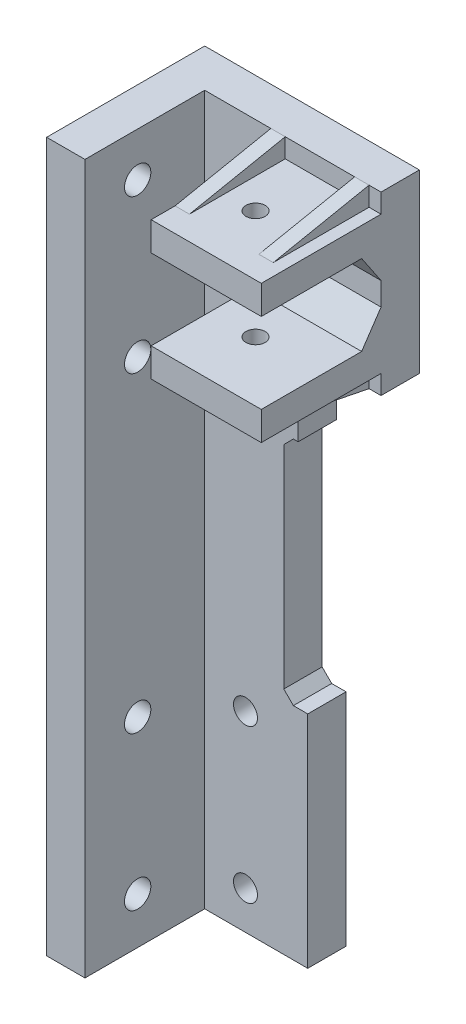
from build123d import *

# Parameters (mm, degrees)
SKETCH1_W               = 24.51
SKETCH1_H               = 148
BOSS_EXTRUDE1_DEPTH     = 8
SKETCH2_W               = 8
SKETCH2_H               = 148
BOSS_EXTRUDE2_DEPTH     = 25
SKETCH4_W               = 20.3
SKETCH4_H               = 36.8
BOSS_EXTRUDE3_DEPTH     = 8
SKETCH5_W               = 23
SKETCH5_H               = 6
BOSS_EXTRUDE4_DEPTH     = 25
CUT_EXTRUDE2_REACH      = 151.752
SKETCH6_R               = 2
RIB1_REACH              = 159.03
SKETCH8_WALL_W          = 336.456302216
SKETCH8_WALL_H          = 3
MIRROR2_COPY_1_REACH    = 159.03
MIRROR2_COPY_1_SKETCH_W = 336.456302216
MIRROR2_COPY_1_SKETCH_H = 3
SKETCH3_R               = 2.5
CUT_EXTRUDE1_DEPTH      = 10
SKETCH12_R              = 2.75
CUT_EXTRUDE3_DEPTH      = 8
SKETCH13_W              = 5
SKETCH13_H              = 46
BOSS_EXTRUDE5_DEPTH     = 8
SKETCH14_W              = 3
SKETCH14_H              = 17
BOSS_EXTRUDE6_DEPTH     = 8
CHAMFER1_SIZE           = 2
CHAMFER2_SIZE           = 6
CHAMFER2_SIZE2          = 4.047051101


with BuildPart() as part:
    # Sketch1 → Boss-Extrude1 (new body)
    with BuildSketch(Plane.XY):
        with Locations((-12.255, 74)):
            Rectangle(SKETCH1_W, SKETCH1_H)
    extrude(amount=BOSS_EXTRUDE1_DEPTH)

    # Sketch2 → Boss-Extrude2 (add)
    with BuildSketch(Plane.XY.offset(8)):
        with Locations((-20.51, 74)):
            Rectangle(SKETCH2_W, SKETCH2_H)
    extrude(amount=BOSS_EXTRUDE2_DEPTH)

    # Sketch4 → Boss-Extrude3 (add)
    with BuildSketch(Plane(origin=(0, 0, 0), x_dir=(-1, 0, 0), z_dir=(0, 0, -1))):
        with Locations((-10.15, 129.6)):
            Rectangle(SKETCH4_W, SKETCH4_H)
    extrude(amount=-BOSS_EXTRUDE3_DEPTH)

    # Sketch5 → Boss-Extrude4 (add)
    with BuildSketch(Plane.XY.offset(8)):
        with Locations((8.8, 118.2)):
            Rectangle(SKETCH5_W, SKETCH5_H)
        with Locations((8.8, 141)):
            Rectangle(SKETCH5_W, SKETCH5_H)
    extrude(amount=BOSS_EXTRUDE4_DEPTH)

    # Cut-Extrude2: up to this face of the body (flat: up to its plane)
    cut_extrude2_end = Plane(part.part.faces().sort_by_distance((8.8, 115.2, 20.5))[0])
    # Sketch6 → Cut-Extrude2 (cut, up to the picked face)
    with BuildSketch(Plane(origin=(0, 144, 0), x_dir=(1, 0, 0), z_dir=(0, 1, 0)), mode=Mode.PRIVATE) as cut_extrude2_sk1:
        with Locations(Location((6.6, -20.5, 0), (0, 0, 270))):
            Circle(SKETCH6_R)
    cut_extrude2_tool1 = split(extrude(cut_extrude2_sk1.sketch, amount=-CUT_EXTRUDE2_REACH, mode=Mode.PRIVATE), bisect_by=cut_extrude2_end, keep=Keep.BOTH, mode=Mode.PRIVATE)
    add(cut_extrude2_tool1.solids().sort_by(Axis((6.6, 144, 20.5), (0, -1, 0)))[0], mode=Mode.SUBTRACT)

    # Sketch8 wall → Rib1 (add, up to next)
    with BuildSketch(Plane(origin=(16.3, 146, 18), x_dir=(0, -0.196116135138, 0.980580675691), z_dir=(0, -0.980580675691, -0.196116135138)), mode=Mode.PRIVATE) as rib1_sk1:
        Rectangle(SKETCH8_WALL_W, SKETCH8_WALL_H)
    rib1_tool1 = extrude(rib1_sk1.sketch, amount=RIB1_REACH, mode=Mode.PRIVATE) - part.part
    rib1 = rib1_tool1.solids().sort_by_distance((16.3, 146, 18))[0]
    add(rib1)

    # Mirror1: Rib1 across plane
    add(rib1.mirror(Plane.ZX.offset(129.6)))

    # Mirror2: Rib1 across plane
    add(rib1.mirror(Plane.ZY.offset(-7.55)))

    # Mirror2 copy 1 sketch → Mirror2 copy 1 (add, up to next)
    with BuildSketch(Plane(origin=(-1.2, 113.2, 18), x_dir=(0, 0.196116135138, 0.980580675691), z_dir=(0, 0.980580675691, -0.196116135138)), mode=Mode.PRIVATE) as mirror2_copy_1_sk1:
        Rectangle(MIRROR2_COPY_1_SKETCH_W, MIRROR2_COPY_1_SKETCH_H)
    mirror2_copy_1_tool1 = extrude(mirror2_copy_1_sk1.sketch, amount=MIRROR2_COPY_1_REACH, mode=Mode.PRIVATE) - part.part
    add(mirror2_copy_1_tool1.solids().sort_by_distance((-1.2, 113.2, 18))[0])

    # Sketch3 → Cut-Extrude1 (cut)
    with BuildSketch(Plane.XY.offset(8)):
        with Locations((-8, 8)):
            Circle(SKETCH3_R)
        with Locations((-8, 40)):
            Circle(SKETCH3_R)
        with Locations((-8, 100)):
            Circle(SKETCH3_R)
        with Locations((-8, 132)):
            Circle(SKETCH3_R)
    extrude(amount=-CUT_EXTRUDE1_DEPTH, mode=Mode.SUBTRACT)

    # Sketch12 → Cut-Extrude3 (cut)
    with BuildSketch(Plane.ZY.offset(24.51)):
        with Locations((22, 138.8)):
            Circle(SKETCH12_R)
        with Locations((22, 106.8)):
            Circle(SKETCH12_R)
        with Locations((22, 41.7)):
            Circle(SKETCH12_R)
        with Locations((22, 9.7)):
            Circle(SKETCH12_R)
    extrude(amount=-CUT_EXTRUDE3_DEPTH, mode=Mode.SUBTRACT)

    # Sketch13 → Boss-Extrude5 (add)
    with BuildSketch(Plane(origin=(0, 0, 0), x_dir=(-1, 0, 0), z_dir=(0, 0, -1))):
        with Locations((-2.5, 23)):
            Rectangle(SKETCH13_W, SKETCH13_H)
    extrude(amount=-BOSS_EXTRUDE5_DEPTH)

    # Sketch14 → Boss-Extrude6 (add)
    with BuildSketch(Plane(origin=(0, 0, 0), x_dir=(-1, 0, 0), z_dir=(0, 0, -1))):
        with Locations((-1.5, 102.7)):
            Rectangle(SKETCH14_W, SKETCH14_H)
    extrude(amount=-BOSS_EXTRUDE6_DEPTH)

    # Chamfer1
    chamfer1_edges = [part.edges().sort_by_distance(p)[0] for p in [
        (0, 46, 4),
        (3, 111.2, 4),
        (0, 94.2, 4),
    ]]
    chamfer(chamfer1_edges, length=CHAMFER1_SIZE)

    # Chamfer2
    chamfer2_edges = [part.edges().sort_by_distance(p)[0] for p in [
        (8.8, 121.2, 8),
        (8.8, 138, 8),
    ]]
    chamfer2_side = [part.faces().sort_by_distance(p)[0] for p in [
        (-4.974591741, 76.782250606, 8),
    ]]
    chamfer(chamfer2_edges, length=CHAMFER2_SIZE, length2=CHAMFER2_SIZE2, reference=chamfer2_side[0])


solid = part.part
